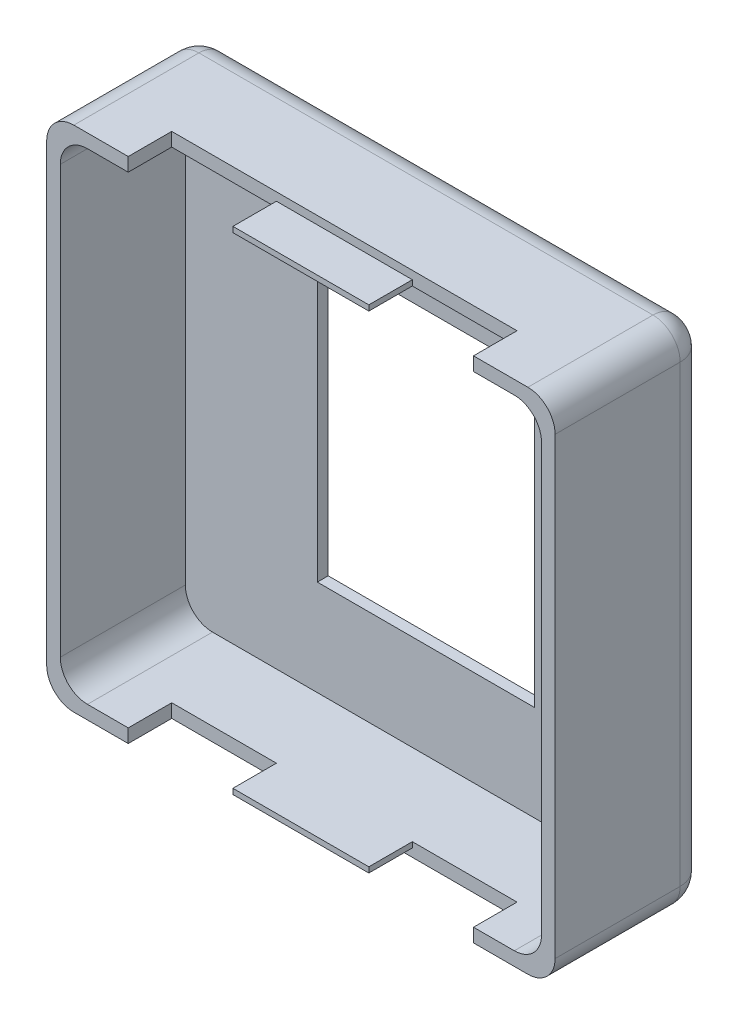
from build123d import *

# Parameters (mm, degrees)
BOSS_EXTRUDE1_DEPTH     = 14.224
CUT_EXTRUDE1_DEPTH      = 11.684
FILLET1_R               = 2.54
SKETCH3_W               = 32.258
SKETCH3_H               = 8.128
CUT_EXTRUDE2_DEPTH      = 1
CUT_EXTRUDE2_DEPTH_BACK = 48.498
SKETCH5_W               = 26.924
SKETCH5_H               = 34.29
CUT_EXTRUDE4_DEPTH      = 1.524
SKETCH6_W               = 20.290608306
SKETCH6_H               = 27.072145664
CUT_EXTRUDE5_DEPTH      = 1.524
BOSS_EXTRUDE2_DEPTH     = 0.762
SKETCH8_W               = 12.7
SKETCH8_H               = 0.508
BOSS_EXTRUDE3_DEPTH     = 4.064


with BuildPart() as part:
    # Sketch1 → Boss-Extrude1 (new body)
    with BuildSketch(Plane.XY):
        with BuildLine():
            Line((-21.209, -23.749), (21.209, -23.749))
            ThreePointArc((21.209, -23.749), (23.005051224, -23.005051224), (23.749, -21.209))
            Line((23.749, -21.209), (23.749, 21.209))
            ThreePointArc((23.749, 21.209), (23.005051224, 23.005051224), (21.209, 23.749))
            Line((21.209, 23.749), (-21.209, 23.749))
            ThreePointArc((-21.209, 23.749), (-23.005051224, 23.005051224), (-23.749, 21.209))
            Line((-23.749, 21.209), (-23.749, -21.209))
            ThreePointArc((-23.749, -21.209), (-23.005051224, -23.005051224), (-21.209, -23.749))
        make_face()
    extrude(amount=BOSS_EXTRUDE1_DEPTH)

    # Sketch2 → Cut-Extrude1 (cut)
    with BuildSketch(Plane.XY.offset(14.224)):
        with BuildLine():
            Line((19.939, -22.479), (-19.939, -22.479))
            ThreePointArc((-19.939, -22.479), (-21.735051224, -21.735051224), (-22.479, -19.939))
            Line((-22.479, -19.939), (-22.479, 19.939))
            ThreePointArc((-22.479, 19.939), (-21.735051224, 21.735051224), (-19.939, 22.479))
            Line((-19.939, 22.479), (19.939, 22.479))
            ThreePointArc((19.939, 22.479), (21.735051224, 21.735051224), (22.479, 19.939))
            Line((22.479, 19.939), (22.479, -19.939))
            ThreePointArc((22.479, -19.939), (21.735051224, -21.735051224), (19.939, -22.479))
        make_face()
    extrude(amount=-CUT_EXTRUDE1_DEPTH, mode=Mode.SUBTRACT)

    # Fillet1
    fillet1_edges = [part.edges().sort_by_distance(p)[0] for p in [
        (0, -23.749, 0),
        (-23.005051224, -23.005051224, 0),
        (-23.749, 0, 0),
        (-23.005051224, 23.005051224, 0),
        (0, 23.749, 0),
        (23.005051224, 23.005051224, 0),
        (23.749, 0, 0),
        (23.005051224, -23.005051224, 0),
    ]]
    fillet(fillet1_edges, radius=FILLET1_R)

    # Sketch3 → Cut-Extrude2 (cut, two sides)
    with BuildSketch(Plane(origin=(0, 23.749, 0), x_dir=(1, 0, 0), z_dir=(0, 1, 0))) as cut_extrude2_sk:
        with Locations((0, -14.224)):
            Rectangle(SKETCH3_W, SKETCH3_H)
    extrude(amount=CUT_EXTRUDE2_DEPTH, mode=Mode.SUBTRACT)
    extrude(cut_extrude2_sk.sketch, amount=-CUT_EXTRUDE2_DEPTH_BACK, mode=Mode.SUBTRACT)

    # Sketch5 → Cut-Extrude4 (cut)
    with BuildSketch(Plane(origin=(0, 0, 0), x_dir=(-1, 0, 0), z_dir=(0, 0, -1))):
        Rectangle(SKETCH5_W, SKETCH5_H)
    extrude(amount=-CUT_EXTRUDE4_DEPTH, mode=Mode.SUBTRACT)

    # Sketch6 → Cut-Extrude5 (cut)
    with BuildSketch(Plane(origin=(0, 0, 1.524), x_dir=(-1, 0, 0), z_dir=(0, 0, -1))):
        Rectangle(SKETCH6_W, SKETCH6_H)
    extrude(amount=-CUT_EXTRUDE5_DEPTH, mode=Mode.SUBTRACT)

    # Sketch7 → Boss-Extrude2 (add)
    with BuildSketch(Plane(origin=(0, 0, 0), x_dir=(-1, 0, 0), z_dir=(0, 0, -1))):
        with BuildLine():
            Line((19.939, 17.145), (21.209, 17.145))
            ThreePointArc((21.209, 17.145), (17.399, 20.955), (13.589, 17.145))
            Line((13.589, 17.145), (14.859, 17.145))
            ThreePointArc((14.859, 17.145), (17.399, 19.685), (19.939, 17.145))
        make_face()
        with BuildLine():
            Line((21.209, 15.875), (16.129, 15.875))
            ThreePointArc((16.129, 15.875), (13.589, 13.335), (16.129, 10.795))
            Line((16.129, 10.795), (21.209, 10.795))
            Line((21.209, 10.795), (21.209, 12.065))
            Line((21.209, 12.065), (16.129, 12.065))
            ThreePointArc((16.129, 12.065), (14.859, 13.335), (16.129, 14.605))
            Line((16.129, 14.605), (21.209, 14.605))
            Line((21.209, 14.605), (21.209, 15.875))
        make_face()
        Polygon((13.589, 9.525), (21.209, 9.525), (21.209, 5.715), (19.939, 5.715), (19.939, 8.255), (18.034, 8.255), (18.034, 6.985), (16.764, 6.985), (16.764, 8.255), (13.589, 8.255), align=None)
        Polygon((13.589, 4.445), (21.209, 4.445), (21.209, 0.635), (19.939, 0.635), (19.939, 3.175), (18.034, 3.175), (18.034, 1.905), (16.764, 1.905), (16.764, 3.175), (13.589, 3.175), align=None)
        Polygon((21.209, -0.635), (13.589, -0.635), (13.589, -4.445), (14.859, -4.445), (14.859, -1.905), (21.209, -1.905), align=None)
        Polygon((13.589, -5.715), (21.209, -5.715), (21.209, -9.525), (19.939, -9.525), (19.939, -6.985), (18.034, -6.985), (18.034, -8.255), (16.764, -8.255), (16.764, -6.985), (14.859, -6.985), (14.859, -9.525), (13.589, -9.525), align=None)
        with BuildLine():
            Line((18.9865, -13.97), (18.9865, -15.24))
            ThreePointArc((18.9865, -15.24), (20.558044821, -11.445955179), (16.764, -13.0175))
            ThreePointArc((16.764, -13.0175), (15.137980791, -13.691019209), (15.8115, -12.065))
            Line((15.8115, -12.065), (15.8115, -10.795))
            ThreePointArc((15.8115, -10.795), (14.239955179, -14.589044821), (18.034, -13.0175))
            ThreePointArc((18.034, -13.0175), (19.660019209, -12.343980791), (18.9865, -13.97))
        make_face()
        with BuildLine():
            Line((15.8115, -17.78), (15.8115, -16.51))
            ThreePointArc((15.8115, -16.51), (14.239955179, -20.304044821), (18.034, -18.7325))
            ThreePointArc((18.034, -18.7325), (19.660019209, -18.058980791), (18.9865, -19.685))
            Line((18.9865, -19.685), (18.9865, -20.955))
            ThreePointArc((18.9865, -20.955), (20.558044821, -17.160955179), (16.764, -18.7325))
            ThreePointArc((16.764, -18.7325), (15.137980791, -19.406019209), (15.8115, -17.78))
        make_face()
    extrude(amount=BOSS_EXTRUDE2_DEPTH)

    # Sketch8 → Boss-Extrude3 (add)
    with BuildSketch(Plane.XY.offset(10.16)):
        with Locations((0, 22.733)):
            Rectangle(SKETCH8_W, SKETCH8_H)
        with Locations((0, -22.733)):
            Rectangle(SKETCH8_W, SKETCH8_H)
    extrude(amount=BOSS_EXTRUDE3_DEPTH)


solid = part.part
